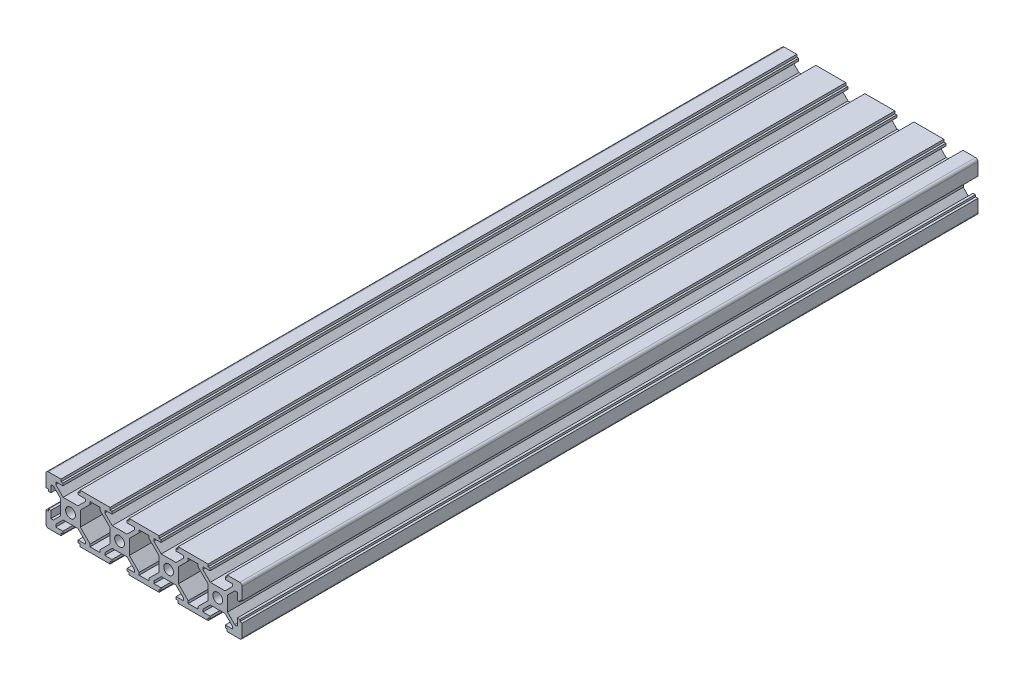
from build123d import *

# Parameters (mm, degrees)
SKETCH_1_R      = 2
EXTRUDE_1_DEPTH = 300
FILLET_1_R      = 1


with BuildPart() as part:
    # Sketch 1 → Extrude 1 (new body)
    with BuildSketch(Plane.XY):
        Polygon((-20, 10), (-13.9, 10), (-13.9, 8.996845012), (-13.1, 8.996845012), (-13.1, 8), (-16.004631122, 8), (-16.004631122, 6.994580616), (-13.010050506, 4), (-6.989949494, 4), (-3.995368878, 6.994580616), (-3.995368878, 8), (-6.9, 8), (-6.9, 8.996845012), (-6.1, 8.996845012), (-6.1, 10), (6.1, 10), (6.1, 8.996845012), (6.9, 8.996845012), (6.9, 8), (3.995368878, 8), (3.995368878, 6.994580616), (6.989949494, 4), (13.010050506, 4), (16.004631122, 6.994580616), (16.004631122, 8), (13.1, 8), (13.1, 8.996845012), (13.9, 8.996845012), (13.9, 10), (26.1, 10), (26.1, 8.996845012), (26.9, 8.996845012), (26.9, 8), (23.995368878, 8), (23.995368878, 6.994580616), (26.989949494, 4), (33.010050506, 4), (36.004631122, 6.994580616), (36.004631122, 8), (33.1, 8), (33.1, 8.996845012), (33.9, 8.996845012), (33.9, 10), (46.1, 10), (46.1, 8.996845012), (46.9, 8.996845012), (46.9, 8), (43.995368878, 8), (43.995368878, 6.994580616), (46.989949494, 4), (53.010050506, 4), (56.004631122, 6.994580616), (56.004631122, 8), (53.1, 8), (53.1, 8.996845012), (53.9, 8.996845012), (53.9, 10), (60, 10), (60, 3.9), (58.996845012, 3.9), (58.996845012, 3.09747601), (58, 3.09747601), (58, 6), (56.989949494, 6), (54, 3.010050506), (54, -3.010050506), (56.989949494, -6), (58, -6), (58, -3.09747601), (58.996845012, -3.09747601), (58.996845012, -3.9), (60, -3.9), (60, -10), (53.9, -10), (53.9, -8.996845012), (53.1, -8.996845012), (53.1, -8), (56.004631122, -8), (56.004631122, -6.994580616), (53.010050506, -4), (46.989949494, -4), (43.995368878, -6.994580616), (43.995368878, -8), (46.9, -8), (46.9, -8.996845012), (46.1, -8.996845012), (46.1, -10), (33.9, -10), (33.9, -8.996845012), (33.1, -8.996845012), (33.1, -8), (36.004631122, -8), (36.004631122, -6.994580616), (33.010050506, -4), (26.989949494, -4), (23.995368878, -6.994580616), (23.995368878, -8), (26.9, -8), (26.9, -8.996845012), (26.1, -8.996845012), (26.1, -10), (13.9, -10), (13.9, -8.996845012), (13.1, -8.996845012), (13.1, -8), (16.004631122, -8), (16.004631122, -6.994580616), (13.010050506, -4), (6.989949494, -4), (3.995368878, -6.994580616), (3.995368878, -8), (6.9, -8), (6.9, -8.996845012), (6.1, -8.996845012), (6.1, -10), (-6.1, -10), (-6.1, -8.996845012), (-6.9, -8.996845012), (-6.9, -8), (-3.995368878, -8), (-3.995368878, -6.994580616), (-6.989949494, -4), (-13.010050506, -4), (-16.004631122, -6.994580616), (-16.004631122, -8), (-13.1, -8), (-13.1, -8.996845012), (-13.9, -8.996845012), (-13.9, -10), (-20, -10), (-20, -3.9), (-18.996845012, -3.9), (-18.996845012, -3.09747601), (-18, -3.09747601), (-18, -6), (-16.989949494, -6), (-14, -3.010050506), (-14, 3.010050506), (-16.989949494, 6), (-18, 6), (-18, 3.09747601), (-18.996845012, 3.09747601), (-18.996845012, 3.9), (-20, 3.9), align=None)
        with Locations((-10, 0)):
            Circle(SKETCH_1_R, mode=Mode.SUBTRACT)
        with Locations((10, 0)):
            Circle(SKETCH_1_R, mode=Mode.SUBTRACT)
        with Locations((30, 0)):
            Circle(SKETCH_1_R, mode=Mode.SUBTRACT)
        with Locations((50, 0)):
            Circle(SKETCH_1_R, mode=Mode.SUBTRACT)
        Polygon((17.984530109, -6.994580616), (17.984530109, -8), (22.015469891, -8), (22.015469891, -6.994580616), (26, -3.010050506), (26, 3.010050506), (22.015469891, 6.994580616), (22.015469891, 8), (17.984530109, 8), (17.984530109, 6.994580616), (14, 3.010050506), (14, -3.010050506), align=None, mode=Mode.SUBTRACT)
        Polygon((2.015469891, -8), (2.015469891, -6.994580616), (6, -3.010050506), (6, 3.010050506), (2.015469891, 6.994580616), (2.015469891, 8), (-2.015469891, 8), (-2.015469891, 6.994580616), (-6, 3.010050506), (-6, -3.010050506), (-2.015469891, -6.994580616), (-2.015469891, -8), align=None, mode=Mode.SUBTRACT)
        Polygon((42.015469891, -8), (37.984530109, -8), (37.984530109, -6.994580616), (34, -3.010050506), (34, 3.010050506), (37.984530109, 6.994580616), (37.984530109, 8), (42.015469891, 8), (42.015469891, 6.994580616), (46, 3.010050506), (46, -3.010050506), (42.015469891, -6.994580616), align=None, mode=Mode.SUBTRACT)
    extrude(amount=EXTRUDE_1_DEPTH)

    # Fillet 1
    fillet_1_edges = [part.edges().sort_by_distance(p)[0] for p in [
        (60, 10, 150),
        (60, -10, 150),
        (-20, -10, 150),
        (-20, 10, 150),
    ]]
    fillet(fillet_1_edges, radius=FILLET_1_R)


solid = part.part
